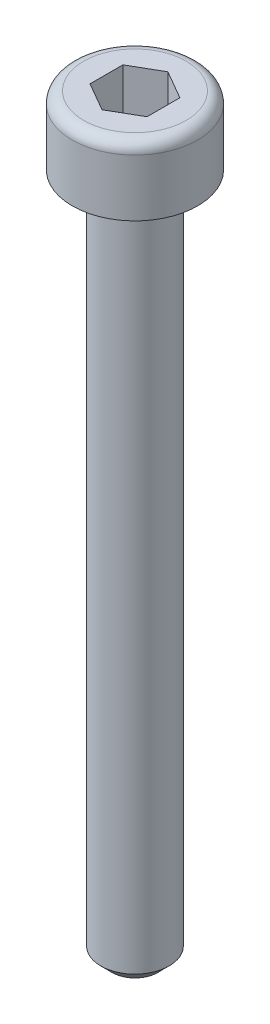
from build123d import *

# Parameters (mm, degrees)
CORTAR_EXTRUIR1_DEPTH = 2
CHAFL_N1_SIZE         = 0.5
REDONDEO1_R           = 0.5


with BuildPart() as part:
    # Croquis1 → Revolución1 (revolve)
    with BuildSketch(Plane.XY):
        Polygon((0, 0), (2.75, 0), (2.75, -3), (1.5, -3), (1.5, -33), (0, -33), align=None)
    revolve(axis=Axis((0, 0, 0), (0, -1, 0)))

    # Croquis2 → Cortar-Extruir1 (cut)
    with BuildSketch(Plane(origin=(0, 0, 0), x_dir=(1, 0, 0), z_dir=(0, 1, 0))):
        Polygon((1.25, 0.721687836), (0, 1.443375673), (-1.25, 0.721687836), (-1.25, -0.721687836), (0, -1.443375673), (1.25, -0.721687836), align=None)
    extrude(amount=-CORTAR_EXTRUIR1_DEPTH, mode=Mode.SUBTRACT)

    # Chaflán1
    chafl_n1_edges = [part.edges().sort_by_distance(p)[0] for p in [
        (-1.5, -33, 0),
    ]]
    chamfer(chafl_n1_edges, length=CHAFL_N1_SIZE)

    # Redondeo1
    redondeo1_edges = [part.edges().sort_by_distance(p)[0] for p in [
        (-2.75, 0, 0),
    ]]
    fillet(redondeo1_edges, radius=REDONDEO1_R)


solid = part.part
